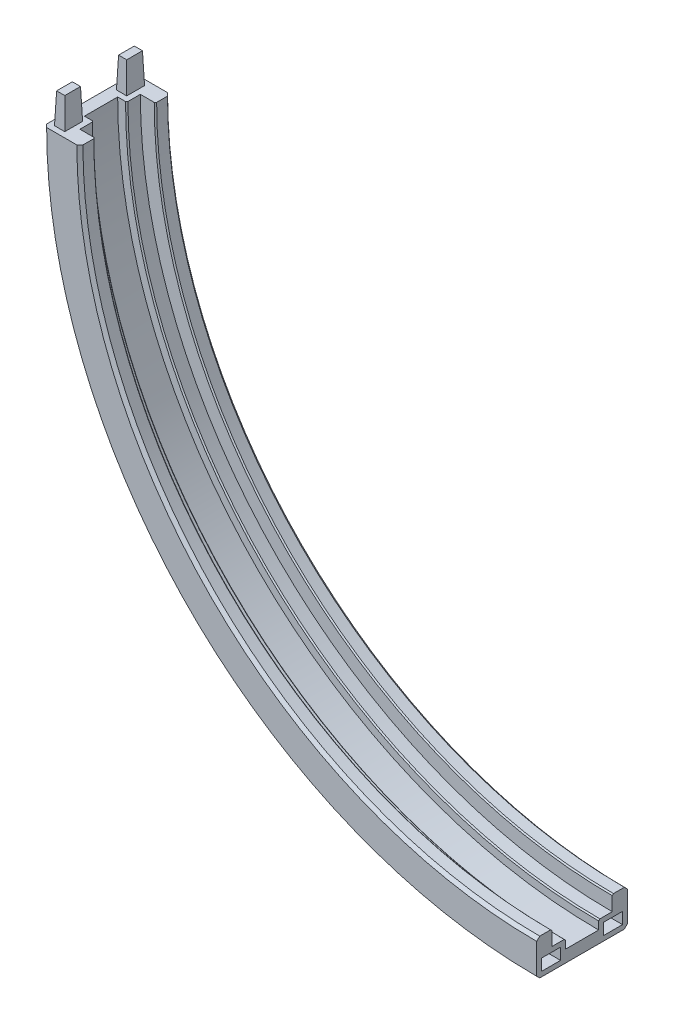
from build123d import *

# Parameters (mm, degrees)
CHANFREIN1_SIZE         = 1
CHANFREIN3_SIZE         = 0.4
ESQUISSE5_W             = 6.3
ESQUISSE5_H             = 3.8
ENL_V_MAT_EXTRU_1_DEPTH = 11
ENL_V_MAT_EXTRU_1_TAPER = 2
ESQUISSE6_W             = 3.4
ESQUISSE6_H             = 5.9
BOSS_EXTRU_2_DEPTH      = 10
BOSS_EXTRU_2_TAPER      = 2


with BuildPart() as part:
    # Balayage1: sweep along a path in Esquisse1
    with BuildLine(Plane.XY) as balayage1_path:
        ThreePointArc((0, 0), (-112.53953952, 46.615403572), (-159.154943092, 159.154943092))
    # Esquisse2 → Balayage1 (sweep)
    with BuildSketch(Plane(origin=(0, 0, 0), x_dir=(0, 0, -1), z_dir=(1, 0, 0))):
        Polygon((-5.5, 0), (5.5, 0), (5.5, 3), (10, 3), (10, 8), (15, 8), (15, -4), (-15, -4), (-15, 8), (-10, 8), (-10, 3), (-5.5, 3), align=None)
    sweep(path=balayage1_path.line)

    # Chanfrein1
    chanfrein1_edges = [part.edges().sort_by_distance(p)[0] for p in [
        (-106.88268527, 52.272257822, 15),
        (-115.367966644, 43.786976448, 15),
        (-115.367966644, 43.786976448, -15),
        (-106.88268527, 52.272257822, -15),
    ]]
    chamfer(chanfrein1_edges, length=CHANFREIN1_SIZE)

    # Chanfrein3
    chanfrein3_edges = [part.edges().sort_by_distance(p)[0] for p in [
        (-106.88268527, 52.272257822, 10),
        (-106.88268527, 52.272257822, -10),
        (-110.418219176, 48.736723916, -5.5),
        (-110.418219176, 48.736723916, 5.5),
    ]]
    chamfer(chanfrein3_edges, length=CHANFREIN3_SIZE)

    # Esquisse5 → Enlèv. mat.-Extru.1 (cut)
    with BuildSketch(Plane(origin=(0, 0, 0), x_dir=(0, 0, -1), z_dir=(1, 0, 0))):
        with Locations((-10.25, -0.5)):
            Rectangle(ESQUISSE5_W, ESQUISSE5_H)
        with Locations((10.25, -0.5)):
            Rectangle(ESQUISSE5_W, ESQUISSE5_H)
    extrude(amount=-ENL_V_MAT_EXTRU_1_DEPTH, taper=ENL_V_MAT_EXTRU_1_TAPER, mode=Mode.SUBTRACT)

    # Esquisse6 → Boss.-Extru.2 (add)
    with BuildSketch(Plane(origin=(0, 159.154943092, 0), x_dir=(1, 0, 0), z_dir=(0, 1, 0))):
        with Locations((-159.654943092, -10.25)):
            Rectangle(ESQUISSE6_W, ESQUISSE6_H)
        with Locations((-159.654943092, 10.25)):
            Rectangle(ESQUISSE6_W, ESQUISSE6_H)
    extrude(amount=BOSS_EXTRU_2_DEPTH, taper=BOSS_EXTRU_2_TAPER)


solid = part.part
